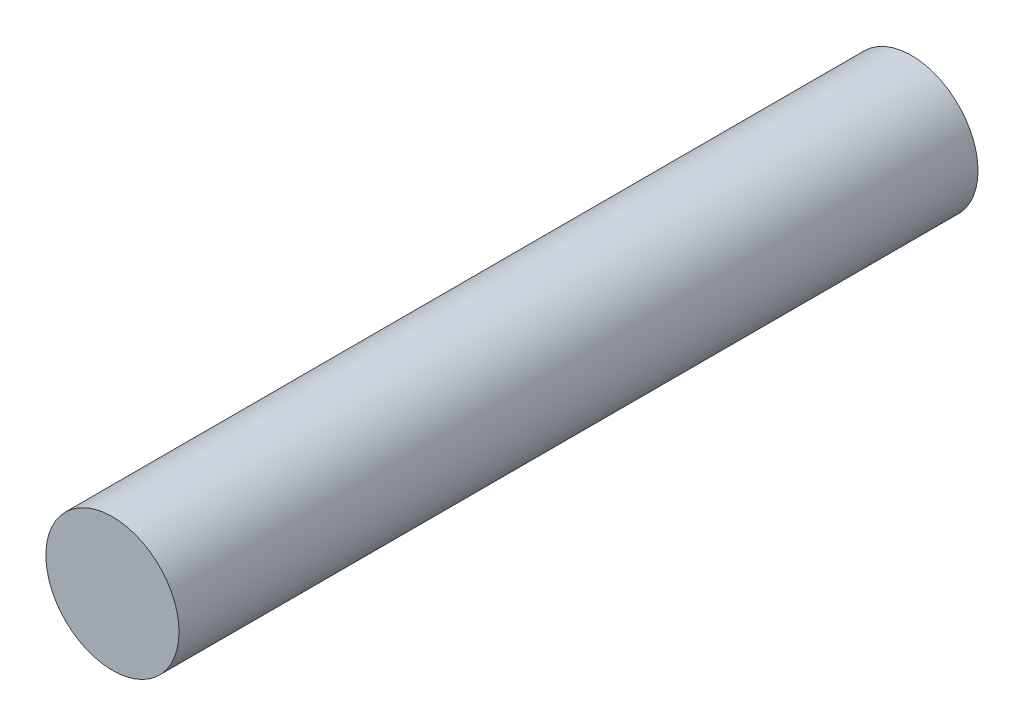
from build123d import *

# Parameters (mm, degrees)
SKETCH1_R           = 3.175
BOSS_EXTRUDE1_DEPTH = 38.1


with BuildPart() as part:
    # Sketch1 → Boss-Extrude1 (new body)
    with BuildSketch(Plane.XY):
        Circle(SKETCH1_R)
    extrude(amount=BOSS_EXTRUDE1_DEPTH)


solid = part.part
